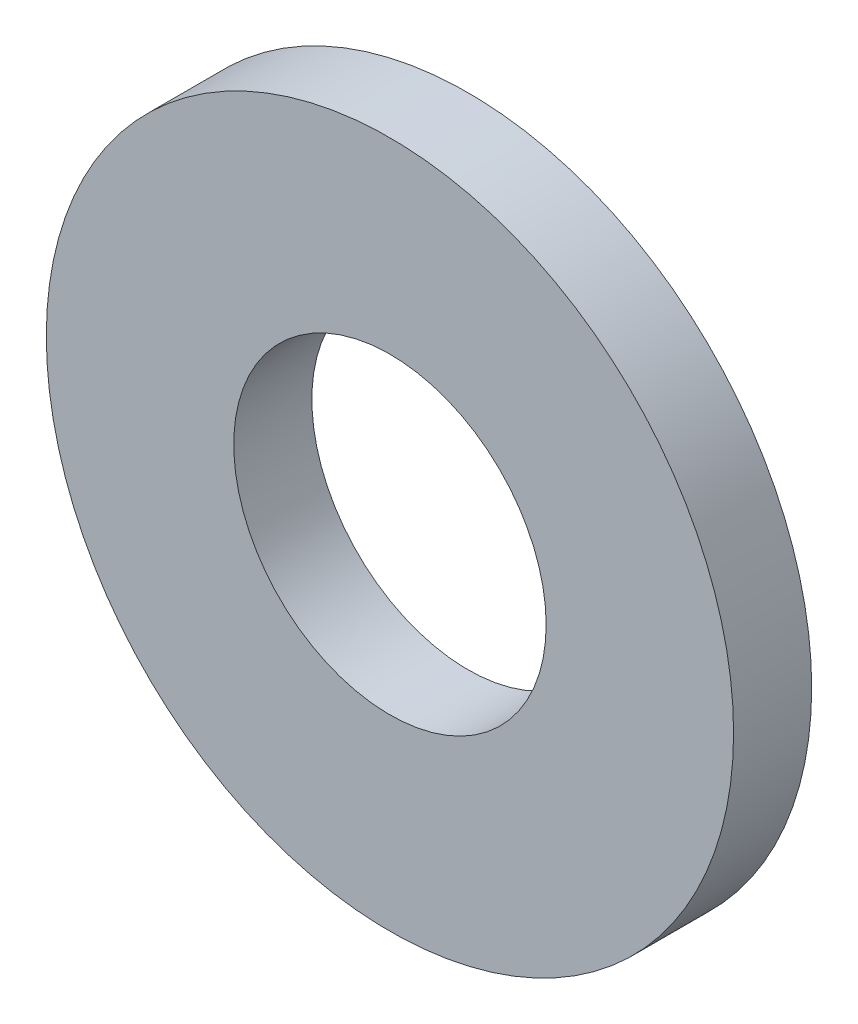
from build123d import *

# Parameters (mm, degrees)
SKETCH1_R      = 5.588
SKETCH1_R_2    = 2.54
EXTRUDE1_DEPTH = 1.27


with BuildPart() as part:
    # Sketch1 → Extrude1 (new body)
    with BuildSketch(Plane.XY):
        Circle(SKETCH1_R)
        Circle(SKETCH1_R_2, mode=Mode.SUBTRACT)
    extrude(amount=-EXTRUDE1_DEPTH)


solid = part.part
